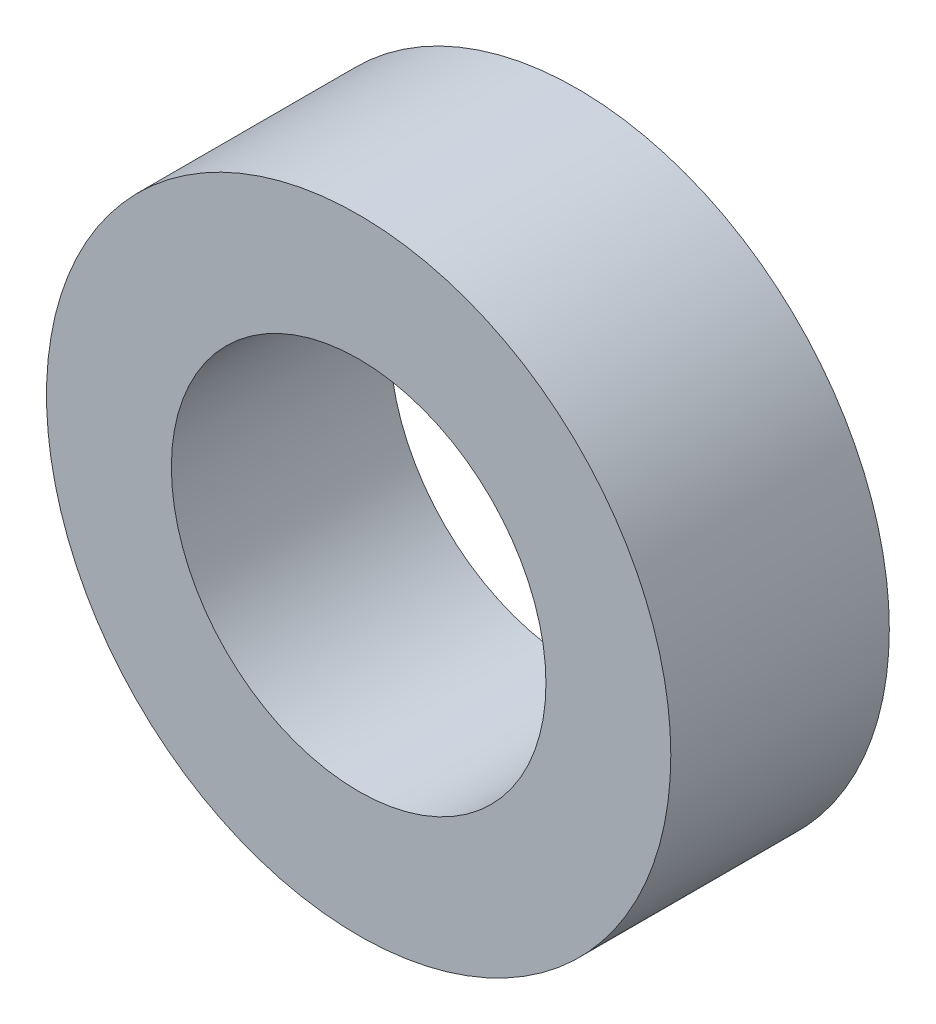
from build123d import *

# Parameters (mm, degrees)
ESQUISSE1_R        = 10
ESQUISSE1_R_2      = 6
BOSS_EXTRU_1_DEPTH = 7


with BuildPart() as part:
    # Esquisse1 → Boss.-Extru.1 (new body)
    with BuildSketch(Plane.XY):
        Circle(ESQUISSE1_R)
        Circle(ESQUISSE1_R_2, mode=Mode.SUBTRACT)
    extrude(amount=BOSS_EXTRU_1_DEPTH)


solid = part.part
